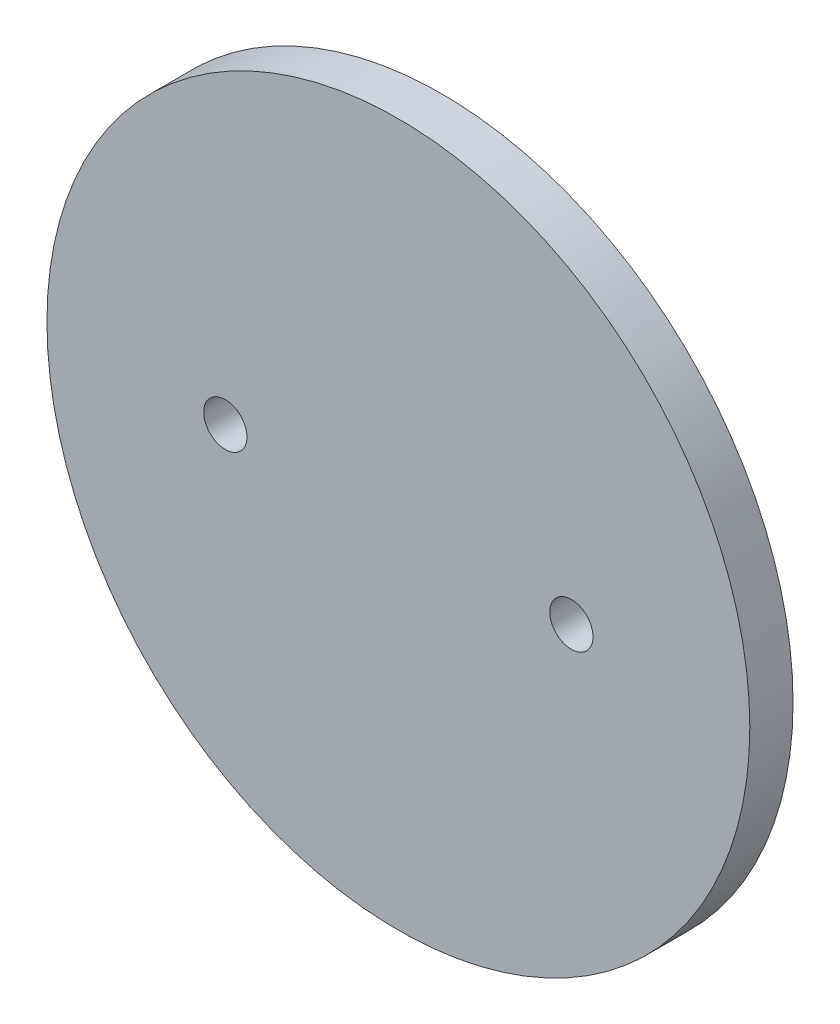
from build123d import *

# Parameters (mm, degrees)
SKETCH1_R           = 20.6375
BOSS_EXTRUDE1_DEPTH = 2.54
CUT_EXTRUDE1_DEPTH  = 3.54


with BuildPart() as part:
    # Sketch1 → Boss-Extrude1 (new body)
    with BuildSketch(Plane.XY):
        Circle(SKETCH1_R)
    extrude(amount=BOSS_EXTRUDE1_DEPTH)

    # Sketch2 → Cut-Extrude1 (cut, through all)
    with BuildSketch(Plane.XY.offset(2.54)):
        with BuildLine():
            ThreePointArc((-8.89, 0), (-10.16, 1.27), (-11.43, 0))
            Line((-11.43, 0), (-8.89, 0))
        make_face()
        with BuildLine():
            Line((-8.89, 0), (-11.43, 0))
            ThreePointArc((-11.43, 0), (-10.16, -1.27), (-8.89, 0))
        make_face()
        with BuildLine():
            ThreePointArc((11.43, 0), (10.16, 1.27), (8.89, 0))
            Line((8.89, 0), (11.43, 0))
        make_face()
        with BuildLine():
            Line((11.43, 0), (8.89, 0))
            ThreePointArc((8.89, 0), (10.16, -1.27), (11.43, 0))
        make_face()
    extrude(amount=-CUT_EXTRUDE1_DEPTH, mode=Mode.SUBTRACT)


solid = part.part
